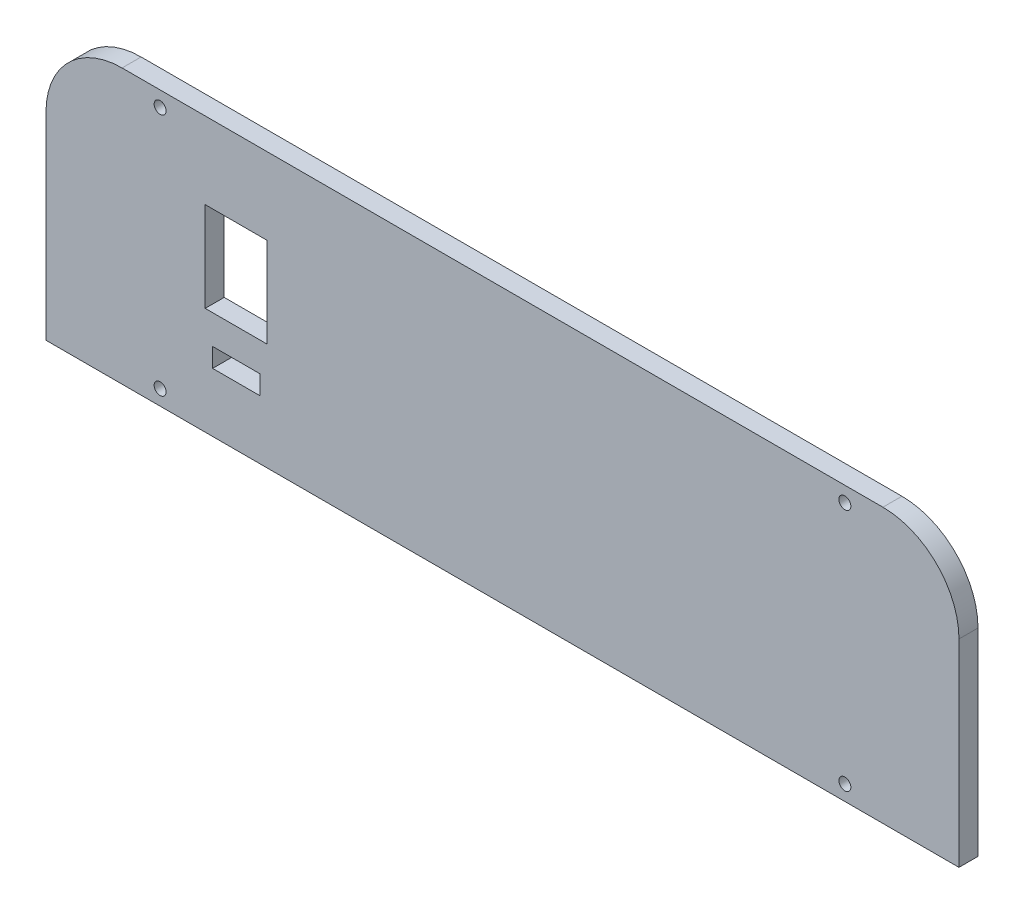
from build123d import *

# Parameters (mm, degrees)
SKETCH1_W           = 152.4
SKETCH1_H           = 45.72
BOSS_EXTRUDE1_DEPTH = 3.175
FILLET1_R           = 12.7
SKETCH2_R           = 0.999998
CUT_EXTRUDE1_DEPTH  = 4.175
SKETCH3_W           = 7.874
SKETCH3_H           = 3.175
CUT_EXTRUDE2_DEPTH  = 4.175
SKETCH4_W           = 10.35
SKETCH4_H           = 15
CUT_EXTRUDE3_DEPTH  = 4.175


with BuildPart() as part:
    # Sketch1 → Boss-Extrude1 (new body)
    with BuildSketch(Plane.XY):
        Rectangle(SKETCH1_W, SKETCH1_H)
    extrude(amount=BOSS_EXTRUDE1_DEPTH)

    # Fillet1
    fillet1_edges = [part.edges().sort_by_distance(p)[0] for p in [
        (-76.2, 22.86, 1.5875),
        (76.2, 22.86, 1.5875),
    ]]
    fillet(fillet1_edges, radius=FILLET1_R)

    # Sketch2 → Cut-Extrude1 (cut, through all)
    with BuildSketch(Plane.XY.offset(3.175)):
        with Locations((-57.15, -20.32)):
            Circle(SKETCH2_R)
        with Locations((-57.15, 20.32)):
            Circle(SKETCH2_R)
        with Locations((57.15, -20.32)):
            Circle(SKETCH2_R)
        with Locations((57.15, 20.32)):
            Circle(SKETCH2_R)
    extrude(amount=-CUT_EXTRUDE1_DEPTH, mode=Mode.SUBTRACT)

    # Sketch3 → Cut-Extrude2 (cut, through all)
    with BuildSketch(Plane.XY.offset(3.175)):
        with Locations((-44.45, -11.43)):
            Rectangle(SKETCH3_W, SKETCH3_H)
    extrude(amount=-CUT_EXTRUDE2_DEPTH, mode=Mode.SUBTRACT)

    # Sketch4 → Cut-Extrude3 (cut, through all)
    with BuildSketch(Plane.XY.offset(3.175)):
        with Locations((-44.45, 2.54)):
            Rectangle(SKETCH4_W, SKETCH4_H)
    extrude(amount=-CUT_EXTRUDE3_DEPTH, mode=Mode.SUBTRACT)


solid = part.part
